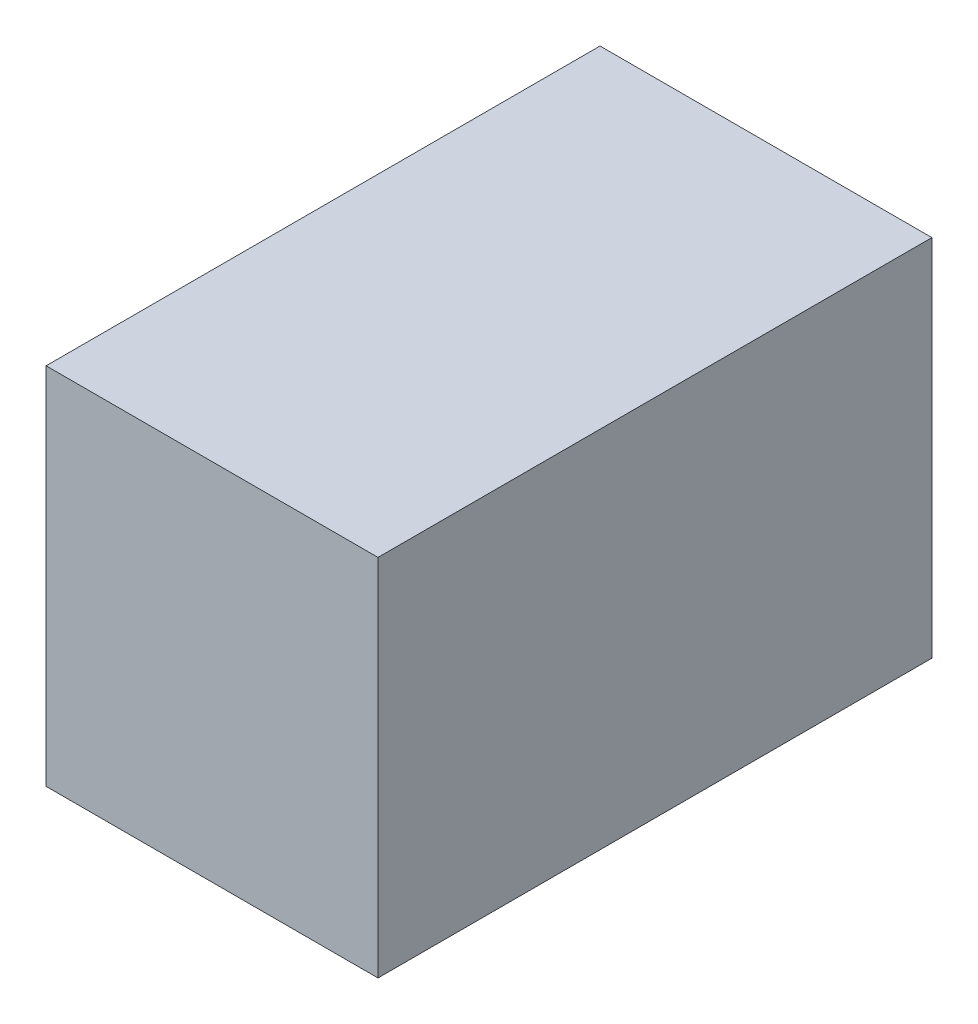
from build123d import *

# Parameters (mm, degrees)
SKETCH4_W           = 31.05
SKETCH4_H           = 19.05
BOSS_EXTRUDE1_DEPTH = 19
SHELL1_T            = 2
SKETCH5_W           = 12
SKETCH5_H           = 19.05
CUT_EXTRUDE1_DEPTH  = 2


with BuildPart() as part:
    # Sketch4 → Boss-Extrude1 (new body)
    with BuildSketch(Plane(origin=(0, 0, 0), x_dir=(0, 0, -1), z_dir=(1, 0, 0))):
        Rectangle(SKETCH4_W, SKETCH4_H)
    extrude(amount=BOSS_EXTRUDE1_DEPTH)

    # Shell1
    shell1_openings = [part.faces().sort_by_distance(p)[0] for p in [
        (0, 0, 0),
    ]]
    offset(amount=SHELL1_T, openings=shell1_openings, kind=Kind.INTERSECTION)

    # Sketch5 → Cut-Extrude1 (cut)
    with BuildSketch(Plane(origin=(0, 0, -17.525), x_dir=(-1, 0, 0), z_dir=(0, 0, -1))):
        with Locations((-6, 0)):
            Rectangle(SKETCH5_W, SKETCH5_H)
    extrude(amount=-CUT_EXTRUDE1_DEPTH, mode=Mode.SUBTRACT)


solid = part.part
